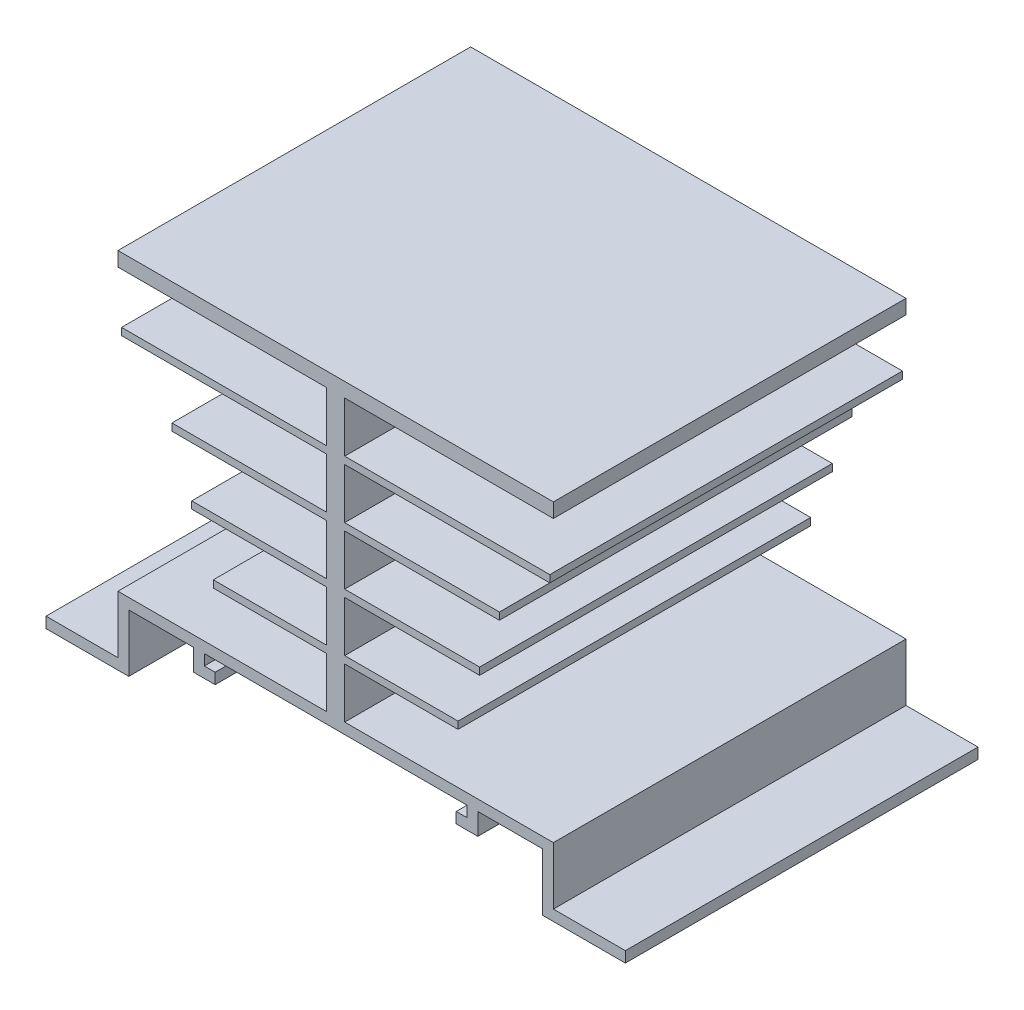
from build123d import *

# Parameters (mm, degrees)
SKETCH1_W           = 60.5
SKETCH1_H           = 42.5
BOSS_EXTRUDE1_DEPTH = 24.5
BOSS_EXTRUDE2_DEPTH = 49
CUT_EXTRUDE1_DEPTH  = 50


with BuildPart() as part:
    # Sketch1 → Boss-Extrude1 (new body, symmetric)
    with BuildSketch(Plane.XY):
        Rectangle(SKETCH1_W, SKETCH1_H)
    extrude(amount=BOSS_EXTRUDE1_DEPTH, both=True)

    # Sketch2 → Boss-Extrude2 (add)
    with BuildSketch(Plane.XY.offset(24.5)):
        Polygon((-30.25, -21.25), (-30.25, -27.75), (-40.25, -27.75), (-40.25, -29.25), (-28.75, -29.25), (-28.75, -21.25), align=None)
        Polygon((-19.75, -21.25), (-19.75, -24.25), (-16.75, -24.25), (-16.75, -22.75), (-18.25, -22.75), (-18.25, -21.25), align=None)
    boss_extrude2 = extrude(amount=-BOSS_EXTRUDE2_DEPTH)

    # Sketch3 → Cut-Extrude1 (cut, through all)
    with BuildSketch(Plane.XY.offset(24.5)):
        Polygon((-30.25, 19.25), (-30.25, -19.75), (-1.25, -19.75), (-1.25, -12.75), (-17, -12.75), (-17, -11.75), (-1.25, -11.75), (-1.25, -4.75), (-20, -4.75), (-20, -3.75), (-1.25, -3.75), (-1.25, 3.25), (-22.75, 3.25), (-22.75, 4.25), (-1.25, 4.25), (-1.25, 11.25), (-29.75, 11.25), (-29.75, 12.25), (-1.25, 12.25), (-1.25, 19.25), align=None)
    cut_extrude1 = extrude(amount=-CUT_EXTRUDE1_DEPTH, mode=Mode.SUBTRACT)

    # Mirror1: Boss-Extrude2, Cut-Extrude1 across plane
    add(boss_extrude2.mirror(Plane(origin=(0, 0, 0), x_dir=(0, 0, 1), z_dir=(1, 0, 0))))
    add(cut_extrude1.mirror(Plane(origin=(0, 0, 0), x_dir=(0, 0, 1), z_dir=(1, 0, 0))), mode=Mode.SUBTRACT)


solid = part.part
